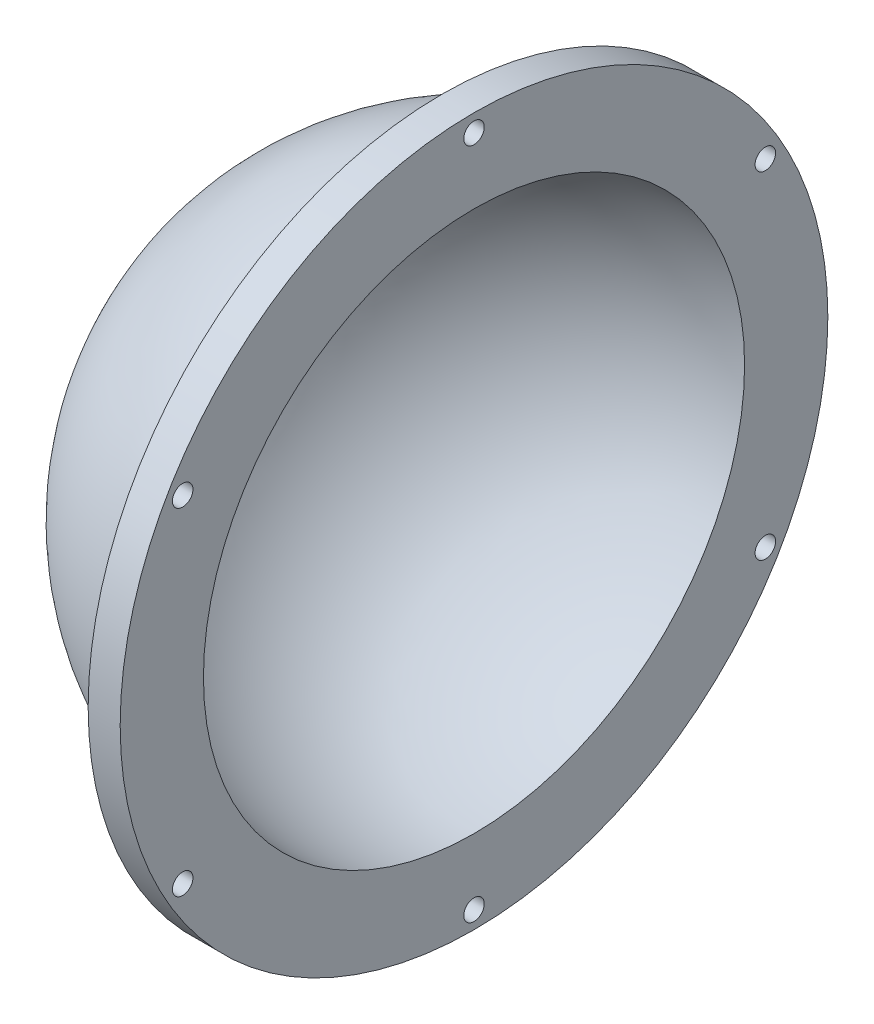
from build123d import *

# Parameters (mm, degrees)
HOLE_WIZARD_3_2_3_2_1_D = 3.2


with BuildPart() as part:
    # 草图1 → 旋转1 (revolve)
    with BuildSketch(Plane.XY):
        with BuildLine():
            Line((0, 42.25), (0, 55.25))
            Line((0, 55.25), (-5, 55.25))
            Line((-5, 55.25), (-5, 46.984704958))
            ThreePointArc((-5, 46.984704958), (-35.134118034, 31.593610905), (-47.25, 0))
            Line((-47.25, 0), (-42.25, 0))
            ThreePointArc((-42.25, 0), (-29.875261505, 29.875261505), (0, 42.25))
        make_face()
    revolve(axis=Axis((0, 0, 0), (-1, 0, 0)))

    # Ø3.2 (3.2) 直径孔1 (through all)
    with Locations(Plane(origin=(-5, 52.525, 0), x_dir=(0, 0, -1), z_dir=(-1, 0, 0))):
        with Locations((0, 0), (-45.487984334, 26.2625), (-45.487984334, 78.7875), (0, 105.05), (45.487984334, 78.7875), (45.487984334, 26.2625)):
            Hole(HOLE_WIZARD_3_2_3_2_1_D / 2)


solid = part.part
